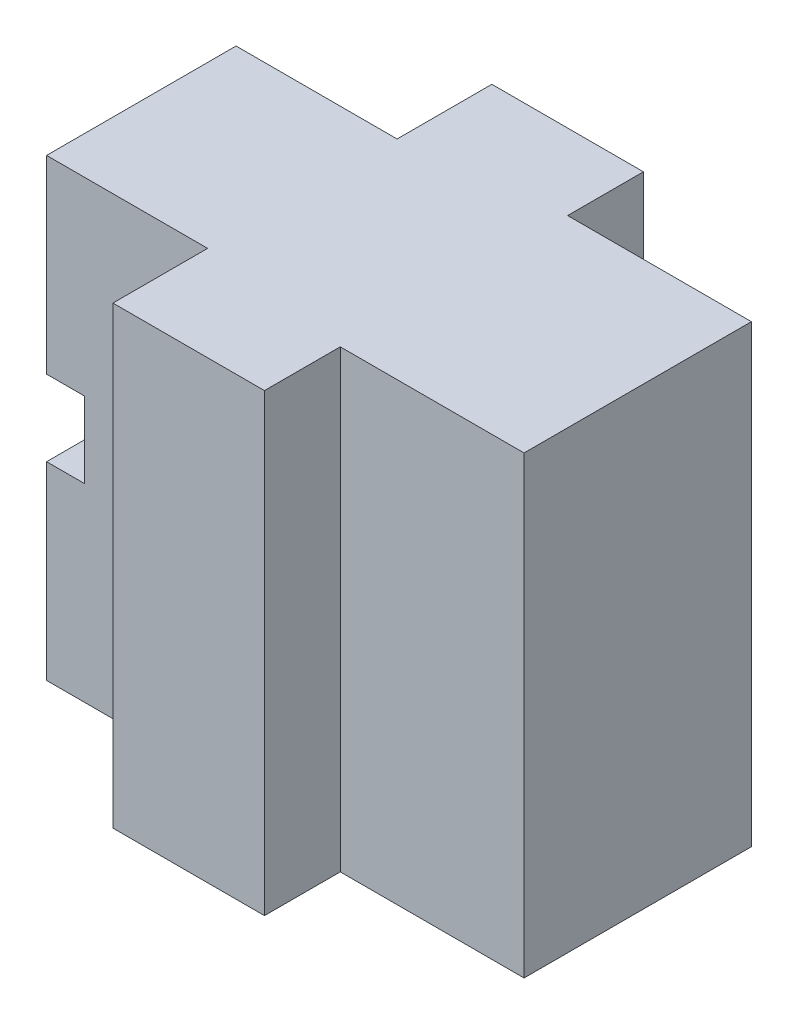
from build123d import *

# Parameters (mm, degrees)
BODY1_DEPTH    = 5
BODY2_SKETCH_W = 8
BODY2_SKETCH_H = 24
BODY2_DEPTH    = 10
CUT_SKETCH_R   = 2.5
CUT_DEPTH      = 10
SKETCH2_W      = 9.7
SKETCH2_H      = 12
L_DETAIL_DEPTH = 24


with BuildPart() as part:
    # Body1_Sketch → Body1 (new body, symmetric)
    with BuildSketch(Plane.XY):
        Polygon((-16.5, -12), (-16.5, -2), (-14.5, -2), (-14.5, 2), (-16.5, 2), (-16.5, 12), (0, 12), (0, -12), align=None)
    extrude(amount=BODY1_DEPTH, both=True)

    # Body2_Sketch → Body2 (add, symmetric)
    with BuildSketch(Plane.XY):
        with Locations((-4, 0)):
            Rectangle(BODY2_SKETCH_W, BODY2_SKETCH_H)
    extrude(amount=BODY2_DEPTH, both=True)

    # Cut_Sketch → Cut (cut)
    with BuildSketch(Plane.ZY.offset(16.5)):
        with Locations((0, 7)):
            Circle(CUT_SKETCH_R)
        with Locations((0, -7)):
            Circle(CUT_SKETCH_R)
    extrude(amount=-CUT_DEPTH, mode=Mode.SUBTRACT)

    # Sketch2 → L-Detail (add)
    with BuildSketch(Plane(origin=(0, 12, 0), x_dir=(-1, 0, 0), z_dir=(0, 1, 0))):
        with Locations((-4.85, 0)):
            Rectangle(SKETCH2_W, SKETCH2_H)
    extrude(amount=-L_DETAIL_DEPTH)


solid = part.part
